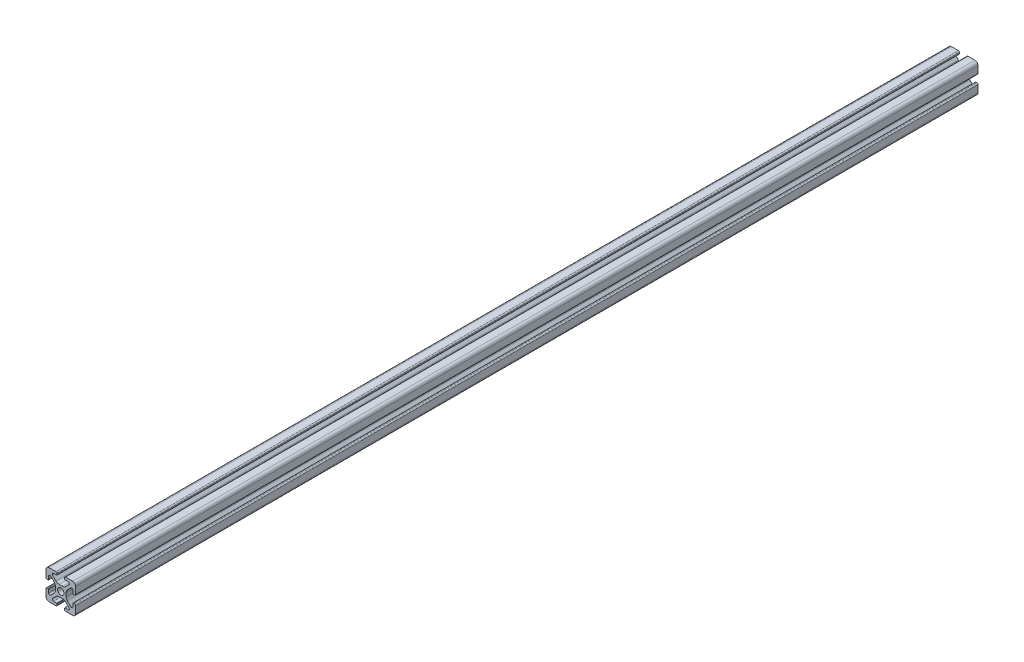
from build123d import *

# Parameters (mm, degrees)
SKETCH1_R      = 2.1463
EXTRUDE1_DEPTH = 304.8


with BuildPart() as part:
    # Sketch1 → Extrude1 (new body, symmetric)
    with BuildSketch(Plane.XY):
        with BuildLine():
            Line((-9.9949, 7.9883), (-9.9949, 3.2893))
            ThreePointArc((-9.9949, 3.2893), (-9.76427588, 2.73252412), (-9.2075, 2.5019))
            Line((-9.2075, 2.5019), (-8.4963, 2.5019))
            ThreePointArc((-8.4963, 2.5019), (-8.280773853, 2.591173853), (-8.1915, 2.8067))
            Line((-8.1915, 2.8067), (-8.1915, 4.9149))
            ThreePointArc((-8.1915, 4.9149), (-7.674065253, 5.689295824), (-6.760603096, 5.507596904))
            Line((-6.760603096, 5.507596904), (-4.505765747, 3.252759555))
            ThreePointArc((-4.505765747, 3.252759555), (-3.856054457, 2.280397894), (-3.627906192, 1.133419111))
            Line((-3.627906192, 1.133419111), (-3.627906192, -1.133419111))
            ThreePointArc((-3.627906192, -1.133419111), (-3.856054457, -2.280397894), (-4.505765747, -3.252759555))
            Line((-4.505765747, -3.252759555), (-6.760603096, -5.507596904))
            ThreePointArc((-6.760603096, -5.507596904), (-7.674065253, -5.689295824), (-8.1915, -4.9149))
            Line((-8.1915, -4.9149), (-8.1915, -2.8067))
            ThreePointArc((-8.1915, -2.8067), (-8.280773853, -2.591173853), (-8.4963, -2.5019))
            Line((-8.4963, -2.5019), (-9.2075, -2.5019))
            ThreePointArc((-9.2075, -2.5019), (-9.76427588, -2.73252412), (-9.9949, -3.2893))
            Line((-9.9949, -3.2893), (-9.9949, -7.9883))
            ThreePointArc((-9.9949, -7.9883), (-9.407180467, -9.407180467), (-7.9883, -9.9949))
            Line((-7.9883, -9.9949), (-3.2893, -9.9949))
            ThreePointArc((-3.2893, -9.9949), (-2.73252412, -9.76427588), (-2.5019, -9.2075))
            Line((-2.5019, -9.2075), (-2.5019, -8.4963))
            ThreePointArc((-2.5019, -8.4963), (-2.591173853, -8.280773853), (-2.8067, -8.1915))
            Line((-2.8067, -8.1915), (-4.9149, -8.1915))
            ThreePointArc((-4.9149, -8.1915), (-5.689295824, -7.674065253), (-5.507596904, -6.760603096))
            Line((-5.507596904, -6.760603096), (-3.252759555, -4.505765747))
            ThreePointArc((-3.252759555, -4.505765747), (-2.280397894, -3.856054457), (-1.133419111, -3.627906192))
            Line((-1.133419111, -3.627906192), (1.133419111, -3.627906192))
            ThreePointArc((1.133419111, -3.627906192), (2.280397894, -3.856054457), (3.252759555, -4.505765747))
            Line((3.252759555, -4.505765747), (5.507596904, -6.760603096))
            ThreePointArc((5.507596904, -6.760603096), (5.689295824, -7.674065253), (4.9149, -8.1915))
            Line((4.9149, -8.1915), (2.8067, -8.1915))
            ThreePointArc((2.8067, -8.1915), (2.591173853, -8.280773853), (2.5019, -8.4963))
            Line((2.5019, -8.4963), (2.5019, -9.2075))
            ThreePointArc((2.5019, -9.2075), (2.73252412, -9.76427588), (3.2893, -9.9949))
            Line((3.2893, -9.9949), (7.9883, -9.9949))
            ThreePointArc((7.9883, -9.9949), (9.407180467, -9.407180467), (9.9949, -7.9883))
            Line((9.9949, -7.9883), (9.9949, -3.2893))
            ThreePointArc((9.9949, -3.2893), (9.76427588, -2.73252412), (9.2075, -2.5019))
            Line((9.2075, -2.5019), (8.4963, -2.5019))
            ThreePointArc((8.4963, -2.5019), (8.280773853, -2.591173853), (8.1915, -2.8067))
            Line((8.1915, -2.8067), (8.1915, -4.9149))
            ThreePointArc((8.1915, -4.9149), (7.674065253, -5.689295824), (6.760603096, -5.507596904))
            Line((6.760603096, -5.507596904), (4.505765747, -3.252759555))
            ThreePointArc((4.505765747, -3.252759555), (3.856054457, -2.280397894), (3.627906192, -1.133419111))
            Line((3.627906192, -1.133419111), (3.627906192, 1.133419111))
            ThreePointArc((3.627906192, 1.133419111), (3.856054457, 2.280397894), (4.505765747, 3.252759555))
            Line((4.505765747, 3.252759555), (6.760603096, 5.507596904))
            ThreePointArc((6.760603096, 5.507596904), (7.674065253, 5.689295824), (8.1915, 4.9149))
            Line((8.1915, 4.9149), (8.1915, 2.8067))
            ThreePointArc((8.1915, 2.8067), (8.280773853, 2.591173853), (8.4963, 2.5019))
            Line((8.4963, 2.5019), (9.2075, 2.5019))
            ThreePointArc((9.2075, 2.5019), (9.76427588, 2.73252412), (9.9949, 3.2893))
            Line((9.9949, 3.2893), (9.9949, 7.9883))
            ThreePointArc((9.9949, 7.9883), (9.407180467, 9.407180467), (7.9883, 9.9949))
            Line((7.9883, 9.9949), (3.2893, 9.9949))
            ThreePointArc((3.2893, 9.9949), (2.73252412, 9.76427588), (2.5019, 9.2075))
            Line((2.5019, 9.2075), (2.5019, 8.4963))
            ThreePointArc((2.5019, 8.4963), (2.591173853, 8.280773853), (2.8067, 8.1915))
            Line((2.8067, 8.1915), (4.9149, 8.1915))
            ThreePointArc((4.9149, 8.1915), (5.689295824, 7.674065253), (5.507596904, 6.760603096))
            Line((5.507596904, 6.760603096), (3.252759555, 4.505765747))
            ThreePointArc((3.252759555, 4.505765747), (2.280397894, 3.856054457), (1.133419111, 3.627906192))
            Line((1.133419111, 3.627906192), (-1.133419111, 3.627906192))
            ThreePointArc((-1.133419111, 3.627906192), (-2.280397894, 3.856054457), (-3.252759555, 4.505765747))
            Line((-3.252759555, 4.505765747), (-5.507596904, 6.760603096))
            ThreePointArc((-5.507596904, 6.760603096), (-5.689295824, 7.674065253), (-4.9149, 8.1915))
            Line((-4.9149, 8.1915), (-2.8067, 8.1915))
            ThreePointArc((-2.8067, 8.1915), (-2.591173853, 8.280773853), (-2.5019, 8.4963))
            Line((-2.5019, 8.4963), (-2.5019, 9.2075))
            ThreePointArc((-2.5019, 9.2075), (-2.73252412, 9.76427588), (-3.2893, 9.9949))
            Line((-3.2893, 9.9949), (-7.9883, 9.9949))
            ThreePointArc((-7.9883, 9.9949), (-9.407180467, 9.407180467), (-9.9949, 7.9883))
        make_face()
        Circle(SKETCH1_R, mode=Mode.SUBTRACT)
    extrude(amount=EXTRUDE1_DEPTH, both=True)


solid = part.part
